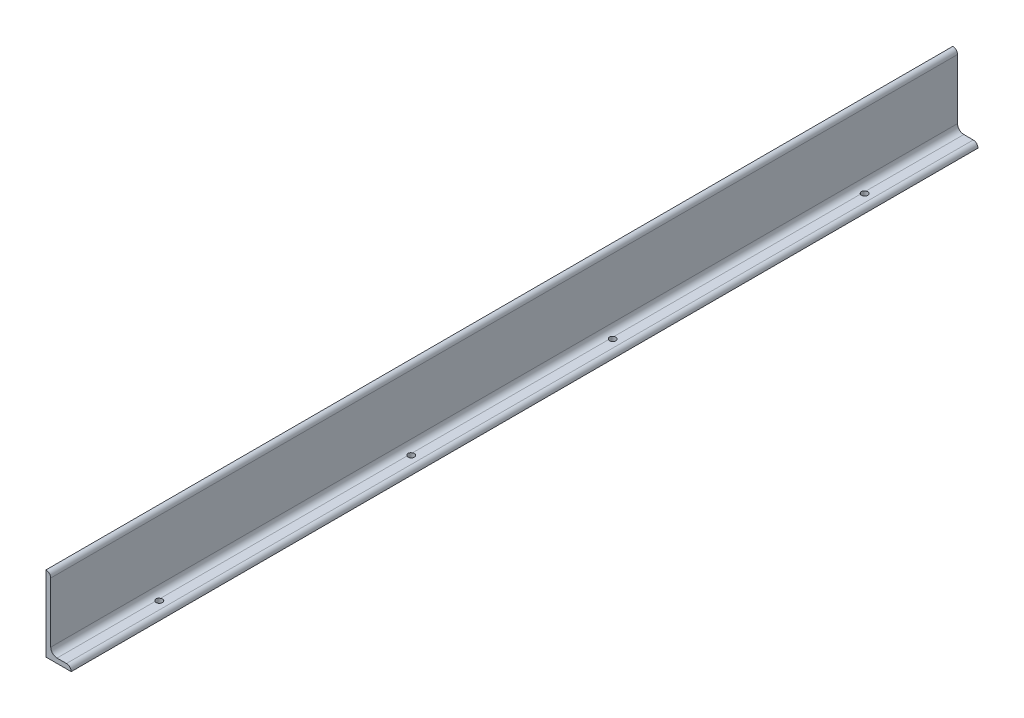
from build123d import *

# Parameters (mm, degrees)
BOSS_EXTRUDE1_DEPTH = 914.4
SKETCH2_R           = 6.35
CUT_EXTRUDE1_DEPTH  = 153.4


with BuildPart() as part:
    # Sketch1 → Boss-Extrude1 (new body, symmetric)
    with BuildSketch(Plane.XY):
        with BuildLine():
            Line((0, 0), (0, 152.4))
            Line((0, 152.4), (0.00508, 152.4))
            ThreePointArc((0.00508, 152.4), (6.736679988, 149.611679988), (9.525, 142.88008))
            Line((9.525, 142.88008), (9.525, 22.225))
            ThreePointArc((9.525, 22.225), (13.244743879, 13.244743879), (22.225, 9.525))
            Line((22.225, 9.525), (41.28008, 9.525))
            ThreePointArc((41.28008, 9.525), (48.011679988, 6.736679988), (50.8, 0.00508))
            Line((50.8, 0.00508), (50.8, 0))
            Line((50.8, 0), (0, 0))
        make_face()
    extrude(amount=BOSS_EXTRUDE1_DEPTH, both=True)

    # Sketch2 → Cut-Extrude1 (cut, through all)
    with BuildSketch(Plane.XZ):
        with Locations((25.4, -711.2)):
            Circle(SKETCH2_R)
        with Locations((25.4, -203.2)):
            Circle(SKETCH2_R)
        with Locations((25.4, 203.2)):
            Circle(SKETCH2_R)
        with Locations((25.4, 711.2)):
            Circle(SKETCH2_R)
    extrude(amount=-CUT_EXTRUDE1_DEPTH, mode=Mode.SUBTRACT)


solid = part.part
